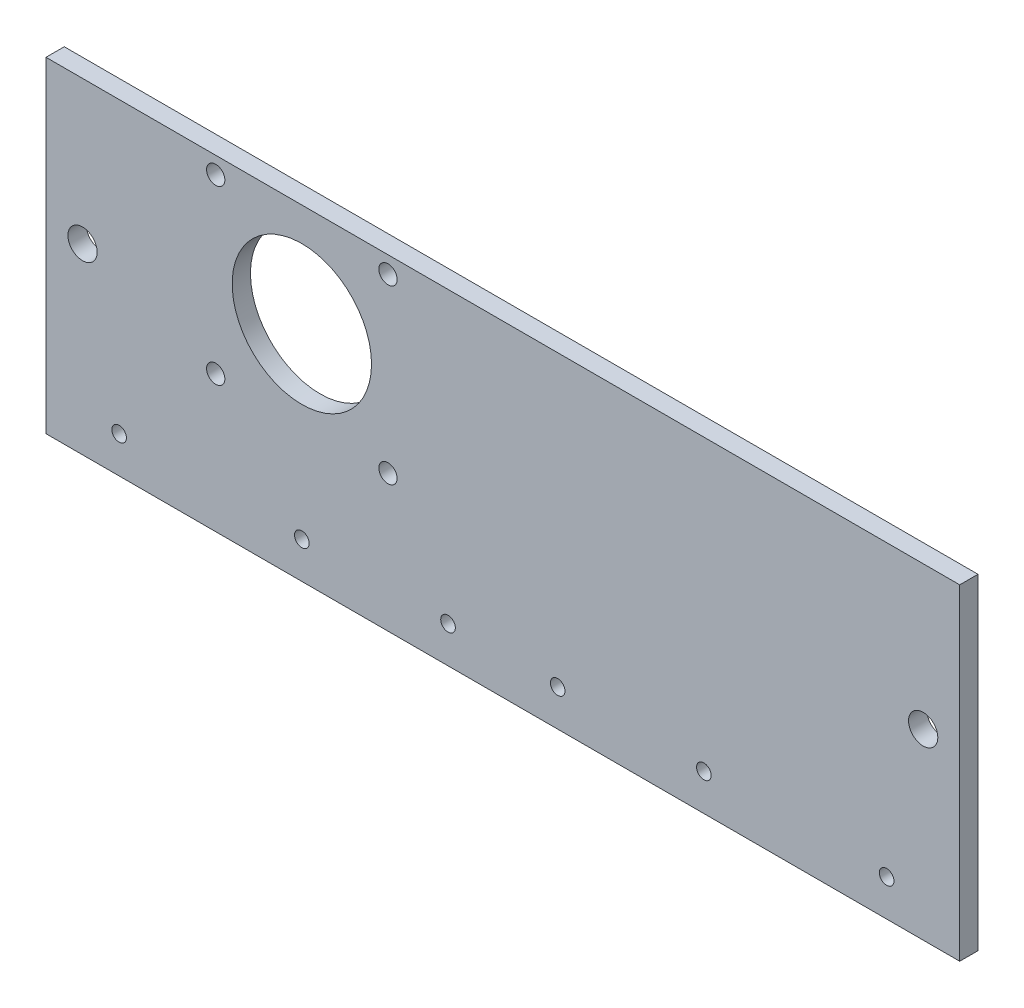
from build123d import *

# Parameters (mm, degrees)
SKIZZE1_W                       = 250
SKIZZE1_H                       = 89.2
AUFSATZ_LINEAR_AUSTRAGEN1_DEPTH = 5
SKIZZE2_R                       = 2
SKIZZE2_R_2                     = 4
SCHNITT_LINEAR_AUSTRAGEN1_DEPTH = 27
SKIZZE3_R                       = 2.5
SCHNITT_LINEAR_AUSTRAGEN2_DEPTH = 27
SKIZZE4_R                       = 19.0625
SCHNITT_LINEAR_AUSTRAGEN3_DEPTH = 27


with BuildPart() as part:
    # Skizze1 → Aufsatz-Linear austragen1 (new body)
    with BuildSketch(Plane.XY):
        with Locations((125, 44.6)):
            Rectangle(SKIZZE1_W, SKIZZE1_H)
    extrude(amount=AUFSATZ_LINEAR_AUSTRAGEN1_DEPTH)

    # Skizze2 → Schnitt-Linear austragen1 (cut)
    with BuildSketch(Plane.XY.offset(5)):
        with Locations((20, 10)):
            Circle(SKIZZE2_R)
        with Locations((70, 10)):
            Circle(SKIZZE2_R)
        with Locations((110, 10)):
            Circle(SKIZZE2_R)
        with Locations((140, 10)):
            Circle(SKIZZE2_R)
        with Locations((180, 10)):
            Circle(SKIZZE2_R)
        with Locations((230, 10)):
            Circle(SKIZZE2_R)
        with Locations((240, 50)):
            Circle(SKIZZE2_R_2)
        with Locations((10, 50)):
            Circle(SKIZZE2_R_2)
    extrude(amount=-SCHNITT_LINEAR_AUSTRAGEN1_DEPTH, mode=Mode.SUBTRACT)

    # Skizze3 → Schnitt-Linear austragen2 (cut)
    with BuildSketch(Plane.XY.offset(5)):
        with Locations((93.57, 84.57)):
            Circle(SKIZZE3_R)
        with Locations((46.43, 84.57)):
            Circle(SKIZZE3_R)
        with Locations((46.43, 37.43)):
            Circle(SKIZZE3_R)
        with Locations((93.57, 37.43)):
            Circle(SKIZZE3_R)
    extrude(amount=-SCHNITT_LINEAR_AUSTRAGEN2_DEPTH, mode=Mode.SUBTRACT)

    # Skizze4 → Schnitt-Linear austragen3 (cut)
    with BuildSketch(Plane.XY.offset(5)):
        with Locations((70, 61)):
            Circle(SKIZZE4_R)
    extrude(amount=-SCHNITT_LINEAR_AUSTRAGEN3_DEPTH, mode=Mode.SUBTRACT)


solid = part.part
